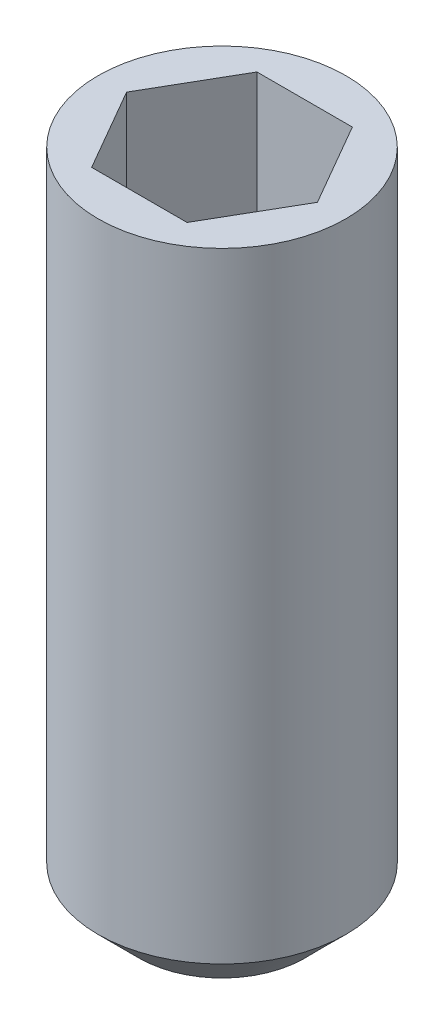
from build123d import *

# Parameters (mm, degrees)
SKETCH1_R           = 1.5
BOSS_EXTRUDE1_DEPTH = 8
CHAMFER1_SIZE       = 0.5
CUT_EXTRUDE1_DEPTH  = 1.5


with BuildPart() as part:
    # Sketch1 → Boss-Extrude1 (new body)
    with BuildSketch(Plane(origin=(0, 0, 0), x_dir=(1, 0, 0), z_dir=(0, 1, 0))):
        Circle(SKETCH1_R)
    extrude(amount=BOSS_EXTRUDE1_DEPTH)

    # Chamfer1
    chamfer1_edges = [part.edges().sort_by_distance(p)[0] for p in [
        (-1.5, 0, 0),
    ]]
    chamfer(chamfer1_edges, length=CHAMFER1_SIZE)

    # Sketch2 → Cut-Extrude1 (cut)
    with BuildSketch(Plane(origin=(0, 8, 0), x_dir=(1, 0, 0), z_dir=(0, 1, 0))):
        Polygon((0.577350269, -1), (1.154700538, 0), (0.577350269, 1), (-0.577350269, 1), (-1.154700538, 0), (-0.577350269, -1), align=None)
    extrude(amount=-CUT_EXTRUDE1_DEPTH, mode=Mode.SUBTRACT)


solid = part.part
